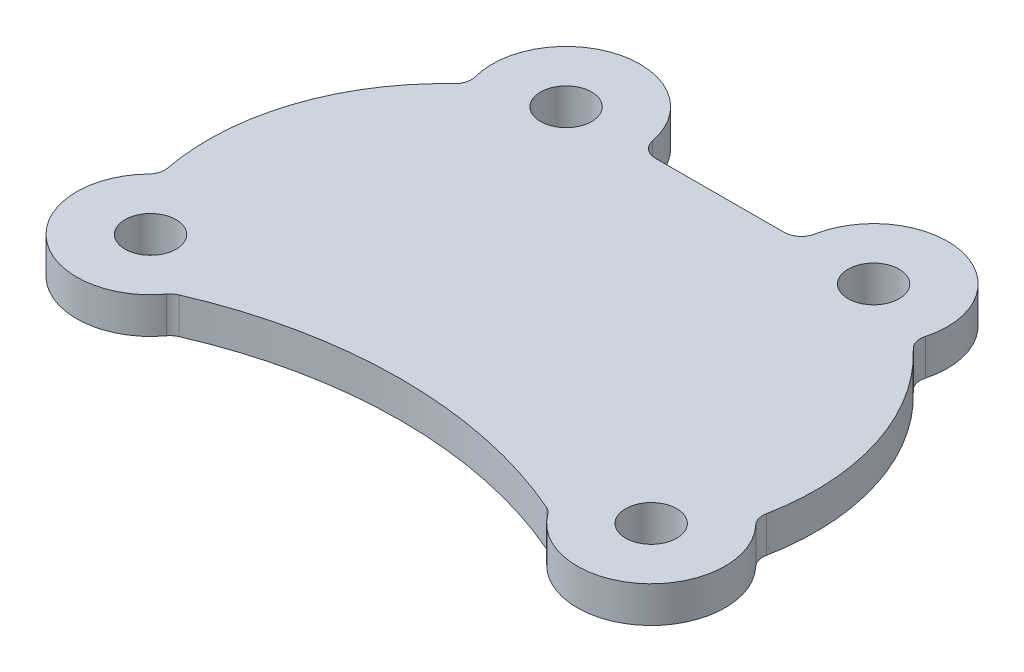
from build123d import *

# Parameters (mm, degrees)
SKETCH1_R      = 4.5
EXTRUDE1_DEPTH = 6.35


with BuildPart() as part:
    # Sketch1 → Extrude1 (new body)
    with BuildSketch(Plane(origin=(0, 0, 0), x_dir=(1, 0, 0), z_dir=(0, 1, 0))):
        with BuildLine():
            Line((32.812063874, 55.953109441), (55.379571692, 55.997622064))
            ThreePointArc((55.379571692, 55.997622064), (57.288458974, 56.688173959), (58.320639688, 58.436120054))
            ThreePointArc((58.320639688, 58.436120054), (74.0236038, 68.667854555), (83.630875665, 52.575253766))
            ThreePointArc((83.630875665, 52.575253766), (83.636046743, 50.974550497), (84.463614261, 49.604364488))
            ThreePointArc((84.463614261, 49.604364488), (95.435770873, 32.172746021), (96.641280568, 11.610735189))
            ThreePointArc((96.641280568, 11.610735189), (96.705732474, 10.194548777), (97.413259954, 8.966077015))
            ThreePointArc((97.413259954, 8.966077015), (96.34909056, -9.964571582), (77.524483139, -7.698282048))
            ThreePointArc((77.524483139, -7.698282048), (76.978786155, -7.130320059), (76.304071652, -6.723962634))
            ThreePointArc((76.304071652, -6.723962634), (44, 0), (11.695928348, -6.723962634))
            ThreePointArc((11.695928348, -6.723962634), (11.021213845, -7.130320059), (10.475516861, -7.698282048))
            ThreePointArc((10.475516861, -7.698282048), (-8.364205722, -9.951887391), (-9.385998192, 8.994611606))
            ThreePointArc((-9.385998192, 8.994611606), (-8.674953739, 10.220222023), (-8.60571551, 11.635464468))
            ThreePointArc((-8.60571551, 11.635464468), (-7.328831083, 32.189532865), (3.700447598, 49.58077127))
            ThreePointArc((3.700447598, 49.58077127), (4.532944762, 50.949409073), (4.542457699, 52.551323698))
            ThreePointArc((4.542457699, 52.551323698), (14.169725803, 68.615280401), (29.859544881, 58.389598348))
            ThreePointArc((29.859544881, 58.389598348), (30.896689666, 56.63923798), (32.812063874, 55.953109441))
        make_face()
        with Locations(Location((17.090937333, 55.947742234, 0), (0, 0, 270))):  # turned: the seam where the file's is
            Circle(SKETCH1_R, mode=Mode.SUBTRACT)
        with Locations(Location((71.090909091, 56.002969963, 0), (0, 0, 270))):  # turned: the seam where the file's is
            Circle(SKETCH1_R, mode=Mode.SUBTRACT)
        with Locations(Location((0, 0, 0), (0, 0, 270))):  # turned: the seam where the file's is
            Circle(SKETCH1_R, mode=Mode.SUBTRACT)
        with Locations(Location((88, 0, 0), (0, 0, 270))):  # turned: the seam where the file's is
            Circle(SKETCH1_R, mode=Mode.SUBTRACT)
    extrude(amount=EXTRUDE1_DEPTH)


solid = part.part
